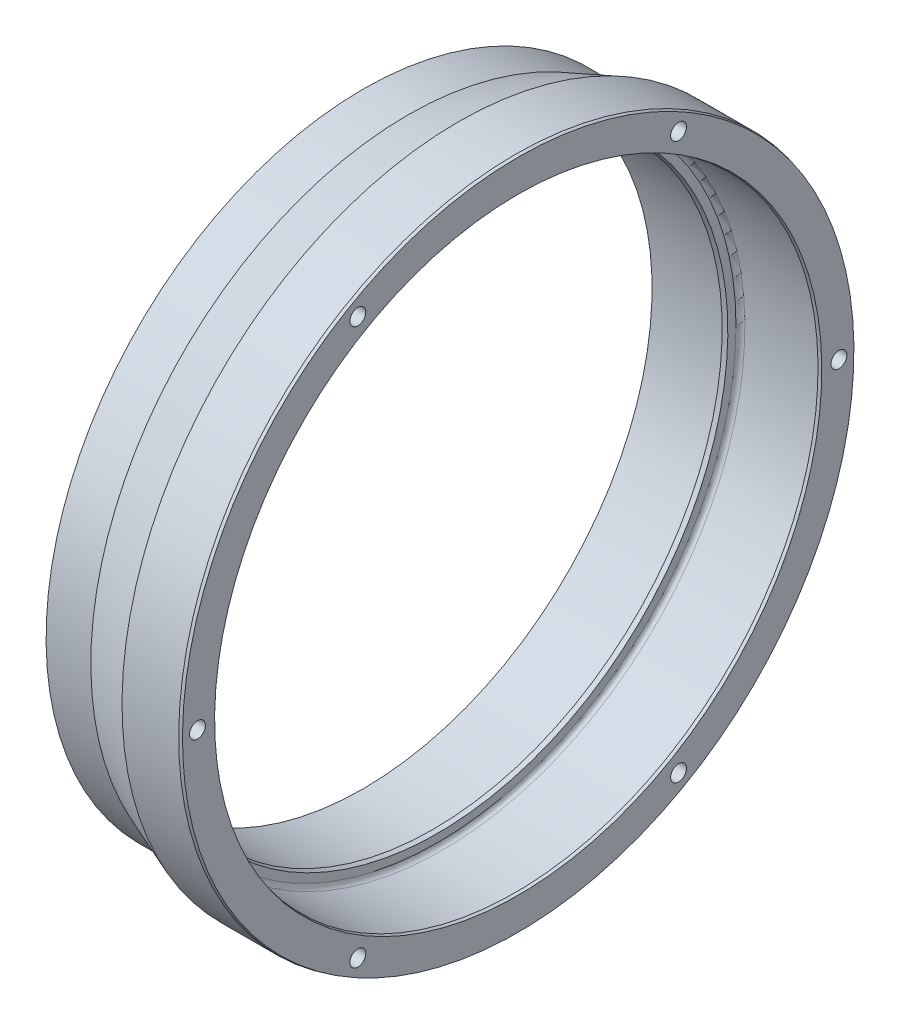
from build123d import *

# Parameters (mm, degrees)
CIRPATTERN1_COUNT = 6


with BuildPart() as part:
    # Sketch1 → Revolve1 (revolve)
    with BuildSketch(Plane.XY):
        with BuildLine():
            Line((-18.796, 53.975), (-10.16, 57.3024))
            Line((-10.16, 57.3024), (-0.508, 57.3024))
            Line((-0.508, 57.3024), (0, 57.16628181))
            Line((0, 57.16628181), (0, 51.69811819))
            Line((0, 51.69811819), (-0.508, 51.562))
            Line((-0.508, 51.562), (-12.954, 51.562))
            ThreePointArc((-12.954, 51.562), (-13.492815367, 51.338815367), (-13.716, 50.8))
            Line((-13.716, 50.8), (-13.716, 49.416677285))
            Line((-13.716, 49.416677285), (-14.478, 49.2125))
            Line((-14.478, 49.2125), (-26.416, 49.2125))
            Line((-26.416, 49.2125), (-26.416, 53.975))
            Line((-26.416, 53.975), (-18.796, 53.975))
        make_face()
    revolve(axis=Axis((0, 0, 0), (-1, 0, 0)))

    # Sketch6 → #6-32 Tapped Hole1 (revolve, cut)
    with BuildSketch(Plane(origin=(0, 0, 54.61), x_dir=(0, 0, -1), z_dir=(0, 1, 0))):
        Polygon((0, 0), (0, 9.70269403), (1.35255, 8.89), (1.35255, 0), align=None)
    f_6_32_tapped_hole1 = revolve(axis=Axis((6.35, 0, 54.61), (-1, 0, 0)), mode=Mode.SUBTRACT)

    # CirPattern1: #6-32 Tapped Hole1 ×6 about axis
    cirpattern1_axis = Axis((0, 0, 0), (1, 0, 0))
    for i in range(1, CIRPATTERN1_COUNT):
        add(f_6_32_tapped_hole1.rotate(cirpattern1_axis, i * 360 / CIRPATTERN1_COUNT), mode=Mode.SUBTRACT)


solid = part.part
